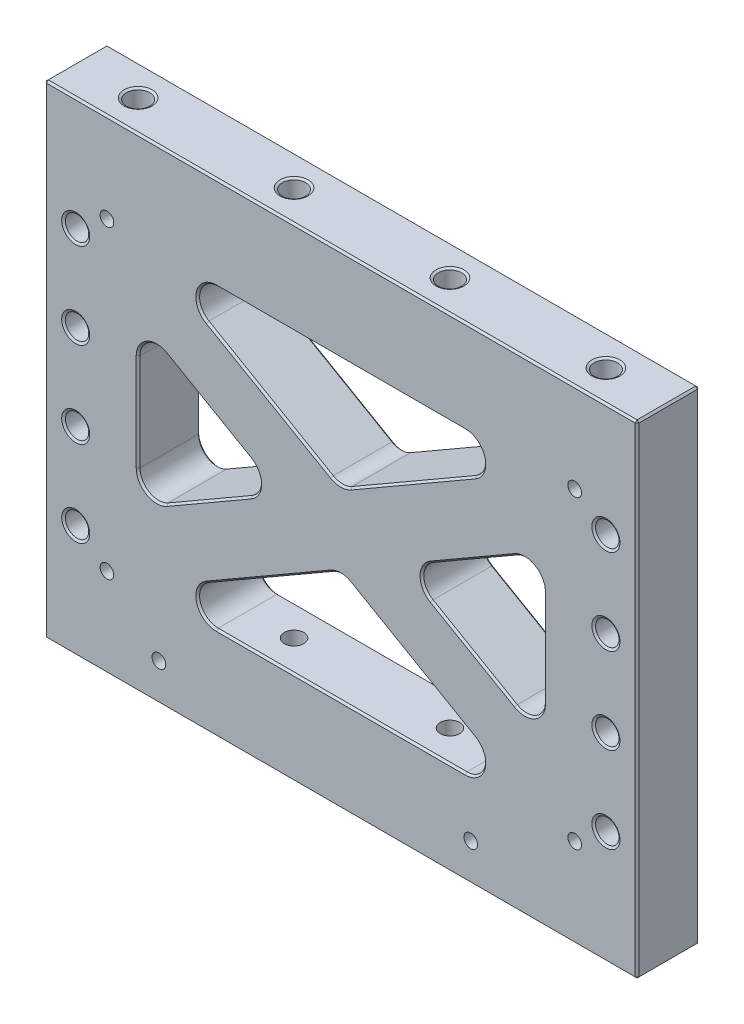
from build123d import *

# Parameters (mm, degrees)
SKETCH1_W                              = 241.3
SKETCH1_H                              = 196.85
EXTRUDE1_DEPTH                         = 25.4
SKETCH8_W                              = 165.1
SKETCH8_H                              = 120.65
EXTRUDE2_DEPTH                         = 26.4
EXTRUDE3_DEPTH                         = 25.4
FILLET1_R                              = 7.62
CHAMFER1_SIZE                          = 0.762
CHAMFER2_SIZE                          = 0.762
F_3_8_16_TAPPED_HOLE1_AT_2_COUNT       = 2
F_3_8_16_TAPPED_HOLE1_AT_2_PITCH       = 63.5
F_3_8_16_TAPPED_HOLE2_AT_2_COUNT       = 2
F_3_8_16_TAPPED_HOLE2_AT_2_PITCH       = 63.5
F_3_8_16_TAPPED_HOLE3_AT_2_COUNT       = 2
F_3_8_16_TAPPED_HOLE3_AT_2_PITCH       = 190.5
F_3_8_16_TAPPED_HOLE4_AT_2_COUNT       = 2
F_3_8_16_TAPPED_HOLE4_AT_2_PITCH       = 190.5
F_7_32_0_21875_VENT_HOLE1_D            = 5.55625
F_3_8_16_TAPPED_HOLE5_AT_2_COUNT       = 2
F_3_8_16_TAPPED_HOLE5_AT_2_PITCH       = 34.925
F_3_8_16_TAPPED_HOLE5_AT_3_COUNT       = 2
F_3_8_16_TAPPED_HOLE5_AT_3_PITCH       = 69.85
F_3_8_16_TAPPED_HOLE5_AT_4_COUNT       = 2
F_3_8_16_TAPPED_HOLE5_AT_4_PITCH       = 104.775
F_3_8_16_TAPPED_HOLE5_AT_5_COUNT       = 2
F_3_8_16_TAPPED_HOLE5_AT_5_PITCH       = 239.980438005
F_3_8_16_TAPPED_HOLE5_AT_6_COUNT       = 2
F_3_8_16_TAPPED_HOLE5_AT_6_PITCH       = 226.918118492
F_3_8_16_TAPPED_HOLE5_AT_7_COUNT       = 2
F_3_8_16_TAPPED_HOLE5_AT_7_PITCH       = 218.706574261
F_3_8_16_TAPPED_HOLE5_AT_8_COUNT       = 2
F_3_8_16_TAPPED_HOLE5_AT_8_PITCH       = 215.9
F_3_8_0_375_DIAMETER_HOLE1_D           = 9.54278
F_3_8_0_375_DIAMETER_HOLE1_DEPTH       = 19.05
F_3_8_0_375_DIAMETER_HOLE1_CSINK_D     = 14.224
F_3_8_0_375_DIAMETER_HOLE1_CSINK_ANGLE = 90
F_3_8_0_375_DIAMETER_HOLE1_TIP         = 2.866940349
EXTRUDE11_DEPTH                        = 19.05
CHAMFER3_SIZE                          = 2.286
F_7_32_0_21875_DIAMETER_HOLE2_D        = 5.55625


with BuildPart() as part:
    # Sketch1 → Extrude1 (new body)
    with BuildSketch(Plane.XY):
        with Locations((0, 98.425)):
            Rectangle(SKETCH1_W, SKETCH1_H)
    extrude(amount=EXTRUDE1_DEPTH)

    # Sketch8 → Extrude2 (cut, through all)
    with BuildSketch(Plane.XY.offset(25.4)):
        with Locations((0, 98.425)):
            Rectangle(SKETCH8_W, SKETCH8_H)
    extrude(amount=-EXTRUDE2_DEPTH, mode=Mode.SUBTRACT)

    # Sketch9 → Extrude3 (add)
    with BuildSketch(Plane.XY.offset(25.4)):
        Polygon((-82.55, 158.75), (-82.55, 131.420567884), (79.085964967, 38.1), (82.55, 38.1), (82.55, 65.429432116), (-79.085964967, 158.75), align=None)
    extrude3 = extrude(amount=-EXTRUDE3_DEPTH)

    # Mirror1: Extrude3 across plane
    add(extrude3.mirror(Plane(origin=(0, 0, 0), x_dir=(0, 0, 1), z_dir=(1, 0, 0))))

    # Fillet1
    fillet1_edges = [part.edges().sort_by_distance(p)[0] for p in [
        (-82.55, 131.420567884, 12.7),
        (79.085964967, 38.1, 12.7),
        (82.55, 65.429432116, 12.7),
        (-79.085964967, 158.75, 12.7),
        (0, 113.089696837, 12.7),
        (25.4, 98.425, 12.7),
        (0, 83.760303163, 12.7),
        (-25.4, 98.425, 12.7),
        (-82.55, 65.429432116, 12.7),
        (79.085964967, 158.75, 12.7),
        (82.55, 131.420567884, 12.7),
        (-79.085964967, 38.1, 12.7),
    ]]
    fillet(fillet1_edges, radius=FILLET1_R)

    # Chamfer1
    chamfer1_edges = [part.edges().sort_by_distance(p)[0] for p in [
        (-53.975, 114.922783942, 0),
        (-53.975, 114.922783942, 25.4),
        (53.975, 114.922783942, 0),
        (53.975, 114.922783942, 25.4),
        (82.55, 98.425, 0),
        (82.55, 98.425, 25.4),
        (53.975, 81.927216058, 0),
        (53.975, 81.927216058, 25.4),
        (58.008092609, 43.747798876, 25.4),
        (58.008092609, 43.747798876, 0),
        (-58.008092609, 43.747798876, 25.4),
        (-58.008092609, 43.747798876, 0),
        (0, 82.58148506, 0),
        (0, 82.58148506, 25.4),
        (58.008092609, 153.102201124, 25.4),
        (58.008092609, 153.102201124, 0),
        (0, 114.26851494, 0),
        (0, 114.26851494, 25.4),
        (-78.74, 72.028545693, 25.4),
        (-78.74, 72.028545693, 0),
        (-78.74, 124.821454307, 25.4),
        (-78.74, 124.821454307, 0),
        (-33.02, 98.425, 25.4),
        (-33.02, 98.425, 0),
        (78.74, 124.821454307, 25.4),
        (78.74, 124.821454307, 0),
        (78.74, 72.028545693, 25.4),
        (78.74, 72.028545693, 0),
        (33.02, 98.425, 25.4),
        (33.02, 98.425, 0),
        (-58.008092609, 153.102201124, 25.4),
        (-58.008092609, 153.102201124, 0),
        (29.133868906, 66.939856107, 25.4),
        (29.133868906, 66.939856107, 0),
        (0, 38.1, 25.4),
        (0, 38.1, 0),
        (-29.133868906, 66.939856107, 25.4),
        (-29.133868906, 66.939856107, 0),
        (0, 158.75, 25.4),
        (0, 158.75, 0),
        (29.133868906, 129.910143893, 25.4),
        (29.133868906, 129.910143893, 0),
        (-29.133868906, 129.910143893, 25.4),
        (-29.133868906, 129.910143893, 0),
        (-53.975, 81.927216058, 0),
        (-53.975, 81.927216058, 25.4),
        (-82.55, 98.425, 0),
        (-82.55, 98.425, 25.4),
    ]]
    chamfer(chamfer1_edges, length=CHAMFER1_SIZE)

    # Chamfer2
    chamfer2_edges = [part.edges().sort_by_distance(p)[0] for p in [
        (120.65, 98.425, 25.4),
        (0, 196.85, 25.4),
        (-120.65, 98.425, 25.4),
        (0, 196.85, 0),
        (120.65, 98.425, 0),
        (0, 0, 0),
        (-120.65, 98.425, 0),
        (0, 0, 25.4),
        (-120.65, 196.85, 12.7),
        (120.65, 196.85, 12.7),
        (120.65, 0, 12.7),
        (-120.65, 0, 12.7),
    ]]
    chamfer(chamfer2_edges, length=CHAMFER2_SIZE)

    # Sketch4 → 3/8-16 Tapped Hole1 (revolve, cut)
    with BuildSketch(Plane(origin=(-31.75, 196.85, 12.7), x_dir=(0, 0, 1), z_dir=(1, 0, 0))):
        Polygon((0, 0), (0, 40.484665582), (3.96875, 38.1), (3.96875, 25.4), (4.7625, 25.4), (4.7625, 0.549926131), (5.715, 0), align=None)
    f_3_8_16_tapped_hole1 = revolve(axis=Axis((-31.75, 203.2, 12.7), (0, -1, 0)), mode=Mode.SUBTRACT)

    # 3/8-16 Tapped Hole1 at 2: 3/8-16 Tapped Hole1 ×2
    with Locations(*[(i * F_3_8_16_TAPPED_HOLE1_AT_2_PITCH, 0, 0) for i in range(1, F_3_8_16_TAPPED_HOLE1_AT_2_COUNT)]):
        add(f_3_8_16_tapped_hole1, mode=Mode.SUBTRACT)

    # Sketch28 → 3/8-16 Tapped Hole2 (revolve, cut)
    with BuildSketch(Plane(origin=(-31.75, 0, 12.7), x_dir=(0, 0, -1), z_dir=(1, 0, 0))):
        Polygon((0, 0), (0, 40.484665582), (3.96875, 38.1), (3.96875, 25.4), (4.7625, 25.4), (4.7625, 0.549926131), (5.715, 0), align=None)
    f_3_8_16_tapped_hole2 = revolve(axis=Axis((-31.75, -6.35, 12.7), (0, 1, 0)), mode=Mode.SUBTRACT)

    # 3/8-16 Tapped Hole2 at 2: 3/8-16 Tapped Hole2 ×2
    with Locations(*[(i * F_3_8_16_TAPPED_HOLE2_AT_2_PITCH, 0, 0) for i in range(1, F_3_8_16_TAPPED_HOLE2_AT_2_COUNT)]):
        add(f_3_8_16_tapped_hole2, mode=Mode.SUBTRACT)

    # Sketch34 → 3/8-16 Tapped Hole3 (revolve, cut)
    with BuildSketch(Plane(origin=(-95.25, 196.85, 12.7), x_dir=(0, 0, 1), z_dir=(1, 0, 0))):
        Polygon((0, 0), (0, 40.484665582), (3.96875, 38.1), (3.96875, 25.4), (4.7625, 25.4), (4.7625, 0.549926131), (5.715, 0), align=None)
    f_3_8_16_tapped_hole3 = revolve(axis=Axis((-95.25, 203.2, 12.7), (0, -1, 0)), mode=Mode.SUBTRACT)

    # 3/8-16 Tapped Hole3 at 2: 3/8-16 Tapped Hole3 ×2
    with Locations(*[(i * F_3_8_16_TAPPED_HOLE3_AT_2_PITCH, 0, 0) for i in range(1, F_3_8_16_TAPPED_HOLE3_AT_2_COUNT)]):
        add(f_3_8_16_tapped_hole3, mode=Mode.SUBTRACT)

    # Sketch36 → 3/8-16 Tapped Hole4 (revolve, cut)
    with BuildSketch(Plane(origin=(95.25, 0, 12.7), x_dir=(0, 0, -1), z_dir=(1, 0, 0))):
        Polygon((0, 0), (0, 40.484665582), (3.96875, 38.1), (3.96875, 25.4), (4.7625, 25.4), (4.7625, 0.549926131), (5.715, 0), align=None)
    f_3_8_16_tapped_hole4 = revolve(axis=Axis((95.25, -6.35, 12.7), (0, 1, 0)), mode=Mode.SUBTRACT)

    # 3/8-16 Tapped Hole4 at 2: 3/8-16 Tapped Hole4 ×2
    with Locations(*[(-i * F_3_8_16_TAPPED_HOLE4_AT_2_PITCH, 0, 0) for i in range(1, F_3_8_16_TAPPED_HOLE4_AT_2_COUNT)]):
        add(f_3_8_16_tapped_hole4, mode=Mode.SUBTRACT)

    # 7/32 (0.21875) Vent Hole1 (through all)
    with Locations(Plane.XY.offset(25.4)):
        with Locations((-95.25, 160.528), (95.25, 160.528), (-95.25, 36.322), (95.25, 36.322)):
            Hole(F_7_32_0_21875_VENT_HOLE1_D / 2)

    # Sketch32 → 3/8-16 Tapped Hole5 (revolve, cut)
    with BuildSketch(Plane(origin=(107.95, 150.8125, 0), x_dir=(0, 1, 0), z_dir=(1, 0, 0))):
        Polygon((0, 0), (0, 25.4), (5.715, 25.4), (4.7625, 24.850073869), (4.7625, 0.549926131), (5.715, 0), align=None)
    f_3_8_16_tapped_hole5 = revolve(axis=Axis((107.95, 150.8125, -6.35), (0, 0, 1)), mode=Mode.SUBTRACT)

    # 3/8-16 Tapped Hole5 at 2: 3/8-16 Tapped Hole5 ×2
    with Locations(*[(0, -i * F_3_8_16_TAPPED_HOLE5_AT_2_PITCH, 0) for i in range(1, F_3_8_16_TAPPED_HOLE5_AT_2_COUNT)]):
        add(f_3_8_16_tapped_hole5, mode=Mode.SUBTRACT)

    # 3/8-16 Tapped Hole5 at 3: 3/8-16 Tapped Hole5 ×2
    with Locations(*[(0, -i * F_3_8_16_TAPPED_HOLE5_AT_3_PITCH, 0) for i in range(1, F_3_8_16_TAPPED_HOLE5_AT_3_COUNT)]):
        add(f_3_8_16_tapped_hole5, mode=Mode.SUBTRACT)

    # 3/8-16 Tapped Hole5 at 4: 3/8-16 Tapped Hole5 ×2
    with Locations(*[(0, -i * F_3_8_16_TAPPED_HOLE5_AT_4_PITCH, 0) for i in range(1, F_3_8_16_TAPPED_HOLE5_AT_4_COUNT)]):
        add(f_3_8_16_tapped_hole5, mode=Mode.SUBTRACT)

    # 3/8-16 Tapped Hole5 at 5: 3/8-16 Tapped Hole5 ×2
    with Locations(*[Vector(-0.899656663, -0.436598086, 0) * (i * F_3_8_16_TAPPED_HOLE5_AT_5_PITCH) for i in range(1, F_3_8_16_TAPPED_HOLE5_AT_5_COUNT)]):
        add(f_3_8_16_tapped_hole5, mode=Mode.SUBTRACT)

    # 3/8-16 Tapped Hole5 at 6: 3/8-16 Tapped Hole5 ×2
    with Locations(*[Vector(-0.951444519, -0.307820285, 0) * (i * F_3_8_16_TAPPED_HOLE5_AT_6_PITCH) for i in range(1, F_3_8_16_TAPPED_HOLE5_AT_6_COUNT)]):
        add(f_3_8_16_tapped_hole5, mode=Mode.SUBTRACT)

    # 3/8-16 Tapped Hole5 at 7: 3/8-16 Tapped Hole5 ×2
    with Locations(*[Vector(-0.987167399, -0.159688844, 0) * (i * F_3_8_16_TAPPED_HOLE5_AT_7_PITCH) for i in range(1, F_3_8_16_TAPPED_HOLE5_AT_7_COUNT)]):
        add(f_3_8_16_tapped_hole5, mode=Mode.SUBTRACT)

    # 3/8-16 Tapped Hole5 at 8: 3/8-16 Tapped Hole5 ×2
    with Locations(*[(-i * F_3_8_16_TAPPED_HOLE5_AT_8_PITCH, 0, 0) for i in range(1, F_3_8_16_TAPPED_HOLE5_AT_8_COUNT)]):
        add(f_3_8_16_tapped_hole5, mode=Mode.SUBTRACT)

    # 3/8 (0.375) Diameter Hole1
    with Locations(Plane.XZ):
        with Locations((-74.083333333, 12.7)):
            CounterSinkHole(F_3_8_0_375_DIAMETER_HOLE1_D / 2, F_3_8_0_375_DIAMETER_HOLE1_CSINK_D / 2, depth=F_3_8_0_375_DIAMETER_HOLE1_DEPTH, counter_sink_angle=F_3_8_0_375_DIAMETER_HOLE1_CSINK_ANGLE)
            with Locations((0, 0, -(F_3_8_0_375_DIAMETER_HOLE1_DEPTH + F_3_8_0_375_DIAMETER_HOLE1_TIP / 2))):  # 118° drill point
                Cone(0, F_3_8_0_375_DIAMETER_HOLE1_D / 2, F_3_8_0_375_DIAMETER_HOLE1_TIP, mode=Mode.SUBTRACT)

    # Sketch47 → Extrude11 (cut)
    with BuildSketch(Plane.XZ):
        with BuildLine():
            Line((51.329166667, 17.47139), (54.504166667, 17.47139))
            ThreePointArc((54.504166667, 17.47139), (59.275556667, 12.7), (54.504166667, 7.92861))
            Line((54.504166667, 7.92861), (51.329166667, 7.92861))
            ThreePointArc((51.329166667, 7.92861), (46.557776667, 12.7), (51.329166667, 17.47139))
        make_face()
    extrude(amount=-EXTRUDE11_DEPTH, mode=Mode.SUBTRACT)

    # Chamfer3
    chamfer3_edges = [part.edges().sort_by_distance(p)[0] for p in [
        (46.557776667, 0, 12.7),
        (52.916666667, 0, 7.92861),
        (59.275556667, 0, 12.7),
        (52.916666667, 0, 17.47139),
    ]]
    chamfer(chamfer3_edges, length=CHAMFER3_SIZE)

    # 7/32 (0.21875) Diameter Hole2 (through all)
    with Locations(Plane.XY.offset(25.4)):
        with Locations((-74.083333333, 15.24), (52.916666667, 15.24)):
            Hole(F_7_32_0_21875_DIAMETER_HOLE2_D / 2)


solid = part.part
